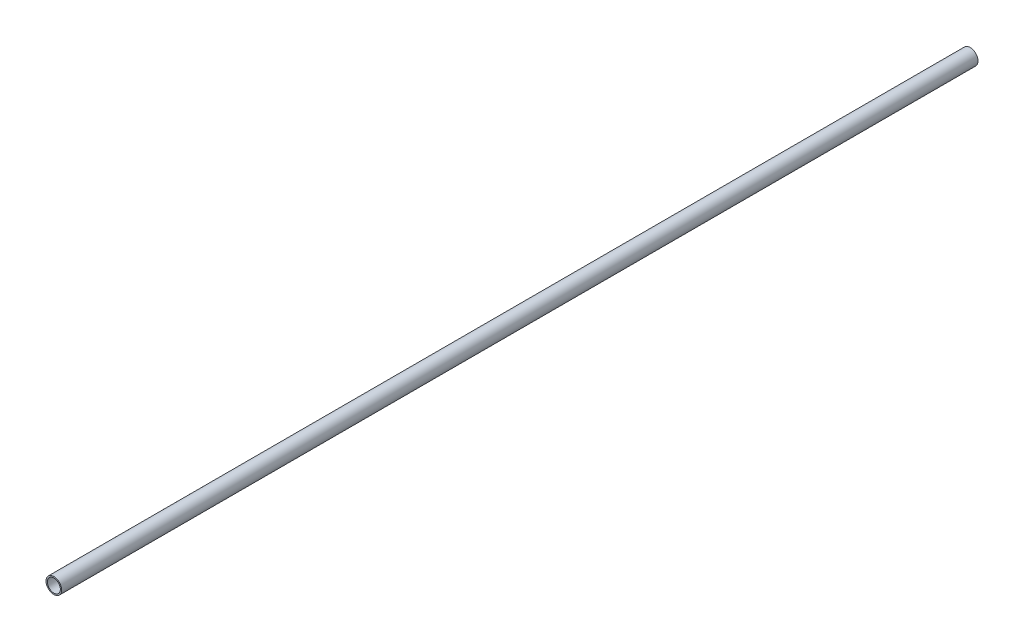
from build123d import *

# Parameters (mm, degrees)
SKETCH1_R           = 21.082
SKETCH1_R_2         = 17.526
BOSS_EXTRUDE1_DEPTH = 2463.8


with BuildPart() as part:
    # Sketch1 → Boss-Extrude1 (new body)
    with BuildSketch(Plane.XY):
        Circle(SKETCH1_R)
        Circle(SKETCH1_R_2, mode=Mode.SUBTRACT)
    extrude(amount=BOSS_EXTRUDE1_DEPTH)


solid = part.part
